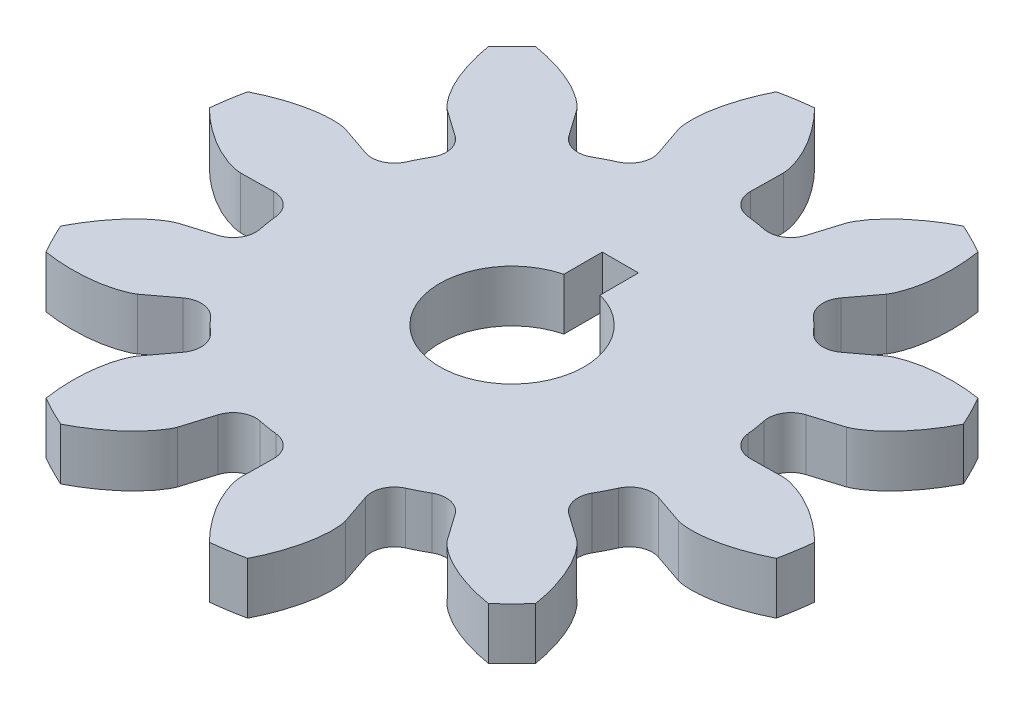
from build123d import *

# Parameters (mm, degrees)
SKETCH3_R                = 18.75
BOSS_EXTRUDE1_DEPTH      = 4.55422
BOSS_EXTRUDE3_DEPTH      = 4.55422
FILLET1_R                = 2
CIRPATTERN2_COUNT        = 10
FILLET1_OF_CIRPATTERN2_R = 2
SKETCH8_R                = 6.35
CUT_EXTRUDE3_DEPTH       = 5.5542201
SKETCH10_W               = 3.175
SKETCH10_H               = 9.525
CUT_EXTRUDE5_DEPTH       = 5.5542201


with BuildPart() as part:
    # Sketch3 → Boss-Extrude1 (new body)
    with BuildSketch(Plane(origin=(0, 0, 0), x_dir=(1, 0, 0), z_dir=(0, 1, 0))):
        with Locations((0.676101669, -1.253289405)):
            Circle(SKETCH3_R)
    extrude(amount=BOSS_EXTRUDE1_DEPTH)

    # Sketch2 → Boss-Extrude3 (add)
    with BuildSketch(Plane(origin=(0, 0, 0), x_dir=(1, 0, 0), z_dir=(0, 1, 0))):
        with BuildLine():
            Line((-6.915605923, 20.978554071), (-3.361279981, 10.569931631))
            Line((-3.361279981, 10.569931631), (0.862285042, 11.237638615))
            Line((0.862285042, 11.237638615), (1.026227194, 22.236416864))
            add(Edge.make_bspline(
                [(-2.560710992, 28.5715835), (-2.540811271, 28.551446798), (-2.090529013, 28.093720072), (-1.315440879, 27.219224694), (-0.399442911, 25.935150009), (0.244866075, 24.793727916), (0.660648874, 23.835449075), (0.919485219, 23.00790033), (1.016287594, 22.49637083), (1.026227194, 22.236416864)],
                knots=[0.17574978, 0.17574978, 0.17574978, 0.17574978, 0.185197235, 0.390016954, 0.565239361, 0.710864469, 0.826892298, 0.91332289, 1, 1, 1, 1], degree=3))
            ThreePointArc((-2.560710992, 28.5715835), (-4.016594882, 28.37741425), (-5.461230381, 28.112220216))
            add(Edge.make_bspline(
                [(-5.461230381, 28.112220216), (-5.473933556, 28.086919722), (-5.768610534, 27.510804195), (-6.225547665, 26.441680506), (-6.703253209, 24.93669575), (-6.962629807, 23.652178289), (-7.062067824, 22.61228993), (-7.052484462, 21.745264643), (-6.986484101, 21.228856258), (-6.915605923, 20.978554071)],
                knots=[0.17574978, 0.17574978, 0.17574978, 0.17574978, 0.185197235, 0.390016954, 0.565239361, 0.710864469, 0.826892298, 0.91332289, 1, 1, 1, 1], degree=3))
        make_face()
    boss_extrude3 = extrude(amount=BOSS_EXTRUDE3_DEPTH)

    # Fillet1
    fillet1_edges = [part.edges().sort_by_distance(p)[0] for p in [
        (-5.383093187, 2.27711, -16.490685846),
        (0.95554852, 2.27711, -17.494628065),
    ]]
    fillet(fillet1_edges, radius=FILLET1_R)

    # CirPattern2: Boss-Extrude3 ×10 about axis
    cirpattern2_axis = Axis((0.676101669, 4.55422, 1.253289405), (0, -1, 0))
    for i in range(1, CIRPATTERN2_COUNT):
        add(boss_extrude3.rotate(cirpattern2_axis, i * 360 / CIRPATTERN2_COUNT))

    # Fillet1 of CirPattern2
    fillet1_of_cirpattern2_edges = [part.edges().sort_by_distance(p)[0] for p in [
        (6.203757028, 2.27711, -16.663393498),
        (11.921928321, 2.27711, -13.7498397),
        (15.679230773, 2.27711, -9.992537247),
        (18.592784572, 2.27711, -4.274365954),
        (19.424019139, 2.27711, 0.973842554),
        (18.42007692, 2.27711, 7.312484261),
        (16.007740249, 2.27711, 12.046961553),
        (11.469773817, 2.27711, 16.584927985),
        (6.735296525, 2.27711, 18.997264655),
        (0.396654818, 2.27711, 20.001206875),
        (-4.851553689, 2.27711, 19.169972307),
        (-10.569724983, 2.27711, 16.256418509),
        (-14.327027435, 2.27711, 12.499116056),
        (-17.240581234, 2.27711, 6.780944763),
        (-18.071815801, 2.27711, 1.532736256),
        (-17.067873582, 2.27711, -4.805905451),
        (-14.655536911, 2.27711, -9.540382744),
        (-10.117570479, 2.27711, -14.078349175),
    ]]
    fillet(fillet1_of_cirpattern2_edges, radius=FILLET1_OF_CIRPATTERN2_R)

    # Sketch8 → Cut-Extrude3 (cut, through all)
    with BuildSketch(Plane(origin=(0, 4.55422, 0), x_dir=(1, 0, 0), z_dir=(0, 1, 0))):
        with Locations((0.676101669, -1.253289405)):
            Circle(SKETCH8_R)
    extrude(amount=-CUT_EXTRUDE3_DEPTH, mode=Mode.SUBTRACT)

    # Sketch10 → Cut-Extrude5 (cut, through all)
    with BuildSketch(Plane(origin=(0, 4.55422, 0), x_dir=(1, 0, 0), z_dir=(0, 1, 0))):
        with Locations((0.676101669, 3.509210595)):
            Rectangle(SKETCH10_W, SKETCH10_H)
    extrude(amount=-CUT_EXTRUDE5_DEPTH, mode=Mode.SUBTRACT)


solid = part.part
